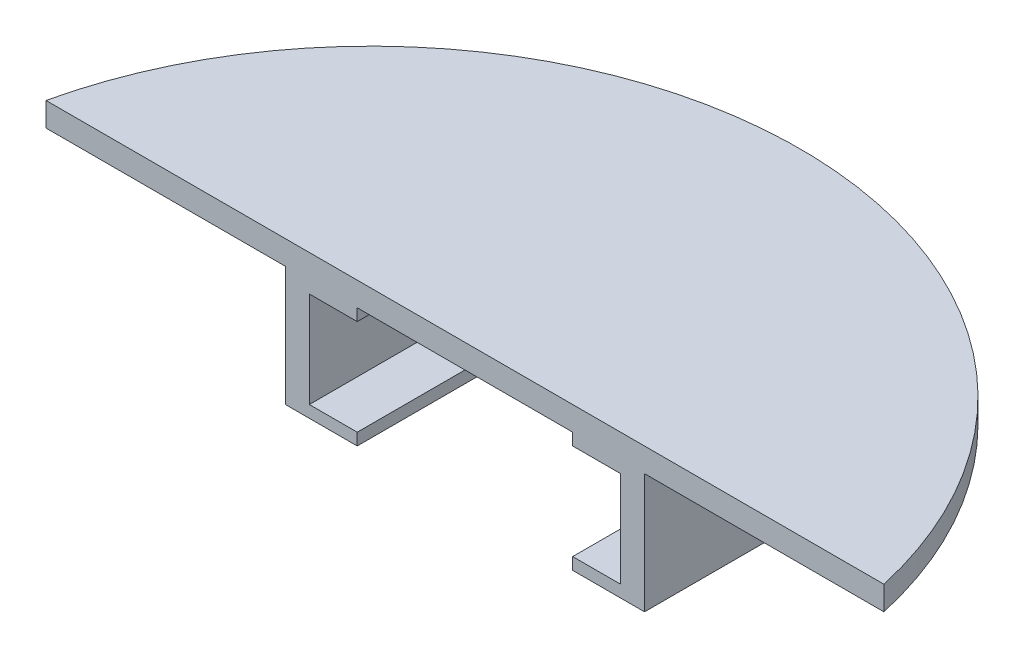
from build123d import *

# Parameters (mm, degrees)
BOSS_EXTRUDE1_DEPTH = 2
BOSS_EXTRUDE3_DEPTH = 9
BOSS_EXTRUDE4_DEPTH = 1
BOSS_EXTRUDE5_START = -9
BOSS_EXTRUDE5_DEPTH = 1


with BuildPart() as part:
    # Sketch1 → Boss-Extrude1 (new body)
    with BuildSketch(Plane(origin=(0, 0, 0), x_dir=(1, 0, 0), z_dir=(0, 1, 0))):
        with BuildLine():
            Line((-35, -13), (35, -13))
            ThreePointArc((35, -13), (0, 15), (-35, -13))
        make_face()
    extrude(amount=BOSS_EXTRUDE1_DEPTH)

    # Sketch1_5 → Boss-Extrude3 (add)
    with BuildSketch(Plane(origin=(0, 0, 0), x_dir=(1, 0, 0), z_dir=(0, 1, 0))):
        with BuildLine():
            ThreePointArc((9.437961603, 11.658682635), (4.766399393, 12.662994302), (6.3e-08, 13))
            ThreePointArc((6.3e-08, 13), (9.192388178, 9.192388133), (13, 0))
            Line((13, 0), (13, -13))
            Line((13, -13), (15, -13))
            Line((15, -13), (15, 0))
            ThreePointArc((15, 0), (13.538268428, 6.458737336), (9.437961603, 11.658682635))
        make_face()
        with BuildLine():
            ThreePointArc((-9.437961603, 11.658682635), (-4.76639933, 12.662994311), (6.3e-08, 13))
            ThreePointArc((6.3e-08, 13), (4.766399393, 12.662994302), (9.437961603, 11.658682635))
            ThreePointArc((9.437961603, 11.658682635), (5.005984494, 14.140018361), (1.09e-07, 15))
            ThreePointArc((1.09e-07, 15), (-5.005984391, 14.140018397), (-9.437961603, 11.658682635))
        make_face()
        with BuildLine():
            Line((-13, -13), (-13, 0))
            ThreePointArc((-13, 0), (-9.192388133, 9.192388178), (6.3e-08, 13))
            ThreePointArc((6.3e-08, 13), (-4.76639933, 12.662994311), (-9.437961603, 11.658682635))
            ThreePointArc((-9.437961603, 11.658682635), (-13.538268428, 6.458737336), (-15, 0))
            Line((-15, 0), (-15, -13))
            Line((-15, -13), (-13, -13))
        make_face()
    extrude(amount=-BOSS_EXTRUDE3_DEPTH)

    # Sketch1_6 → Boss-Extrude4 (add)
    with BuildSketch(Plane(origin=(0, 0, 0), x_dir=(1, 0, 0), z_dir=(0, 1, 0))):
        with BuildLine():
            ThreePointArc((6.3e-08, 13), (-9.192388133, 9.192388178), (-13, 0))
            Line((-13, 0), (-13, -13))
            Line((-13, -13), (-9, -13))
            Line((-9, -13), (-9, 0))
            ThreePointArc((-9, 0), (0, 9), (9, 0))
            Line((9, 0), (9, -13))
            Line((9, -13), (13, -13))
            Line((13, -13), (13, 0))
            ThreePointArc((13, 0), (9.192388178, 9.192388133), (6.3e-08, 13))
        make_face()
    extrude(amount=-BOSS_EXTRUDE4_DEPTH)

    # Sketch1_7 → Boss-Extrude5 (add)
    with BuildSketch(Plane(origin=(0, 0, 0), x_dir=(1, 0, 0), z_dir=(0, 1, 0)).offset(BOSS_EXTRUDE5_START)):
        with BuildLine():
            Line((-13, -13), (-13, 0))
            ThreePointArc((-13, 0), (-9.192388133, 9.192388178), (6.3e-08, 13))
            ThreePointArc((6.3e-08, 13), (-4.76639933, 12.662994311), (-9.437961603, 11.658682635))
            ThreePointArc((-9.437961603, 11.658682635), (-13.538268428, 6.458737336), (-15, 0))
            Line((-15, 0), (-15, -13))
            Line((-15, -13), (-13, -13))
        make_face()
        with BuildLine():
            ThreePointArc((-9.437961603, 11.658682635), (-4.76639933, 12.662994311), (6.3e-08, 13))
            ThreePointArc((6.3e-08, 13), (4.766399393, 12.662994302), (9.437961603, 11.658682635))
            ThreePointArc((9.437961603, 11.658682635), (5.005984494, 14.140018361), (1.09e-07, 15))
            ThreePointArc((1.09e-07, 15), (-5.005984391, 14.140018397), (-9.437961603, 11.658682635))
        make_face()
        with BuildLine():
            ThreePointArc((9.437961603, 11.658682635), (4.766399393, 12.662994302), (6.3e-08, 13))
            ThreePointArc((6.3e-08, 13), (9.192388178, 9.192388133), (13, 0))
            Line((13, 0), (13, -13))
            Line((13, -13), (15, -13))
            Line((15, -13), (15, 0))
            ThreePointArc((15, 0), (13.538268428, 6.458737336), (9.437961603, 11.658682635))
        make_face()
        with BuildLine():
            ThreePointArc((6.3e-08, 13), (-9.192388133, 9.192388178), (-13, 0))
            Line((-13, 0), (-13, -13))
            Line((-13, -13), (-9, -13))
            Line((-9, -13), (-9, 0))
            ThreePointArc((-9, 0), (0, 9), (9, 0))
            Line((9, 0), (9, -13))
            Line((9, -13), (13, -13))
            Line((13, -13), (13, 0))
            ThreePointArc((13, 0), (9.192388178, 9.192388133), (6.3e-08, 13))
        make_face()
    extrude(amount=-BOSS_EXTRUDE5_DEPTH)


solid = part.part
